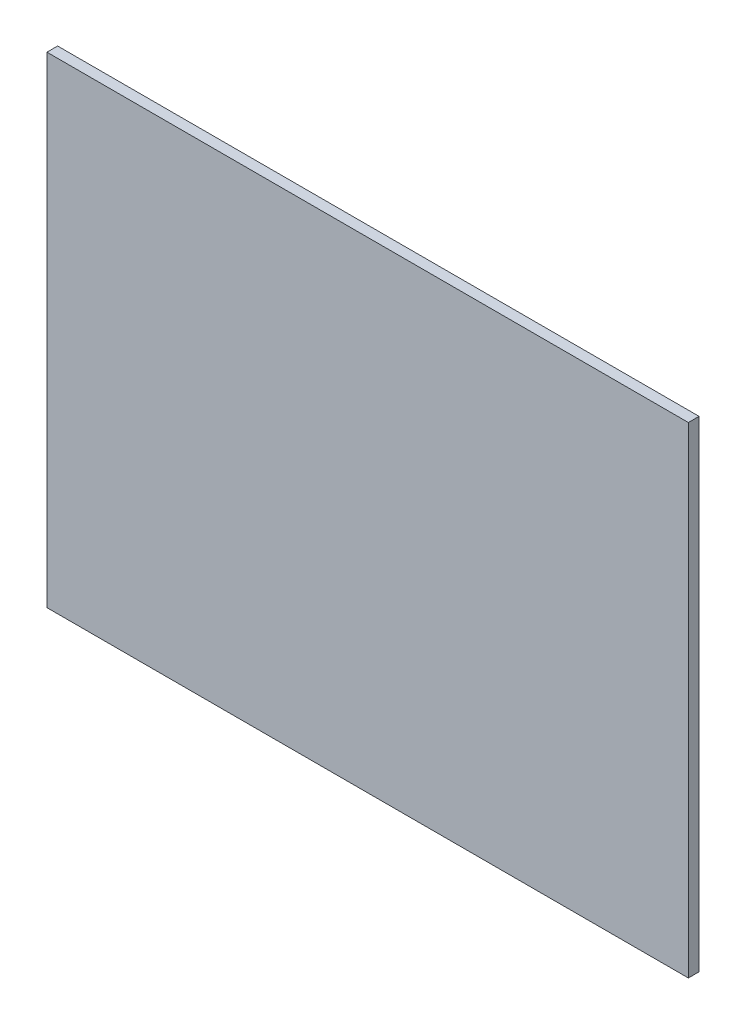
from build123d import *

# Parameters (mm, degrees)
SKETCH1_W           = 60
SKETCH1_H           = 45
BOSS_EXTRUDE1_DEPTH = 1


with BuildPart() as part:
    # Sketch1 → Boss-Extrude1 (new body)
    with BuildSketch(Plane.XY):
        with Locations((4.183266932, 1.703187251)):
            Rectangle(SKETCH1_W, SKETCH1_H)
    extrude(amount=BOSS_EXTRUDE1_DEPTH)


solid = part.part
